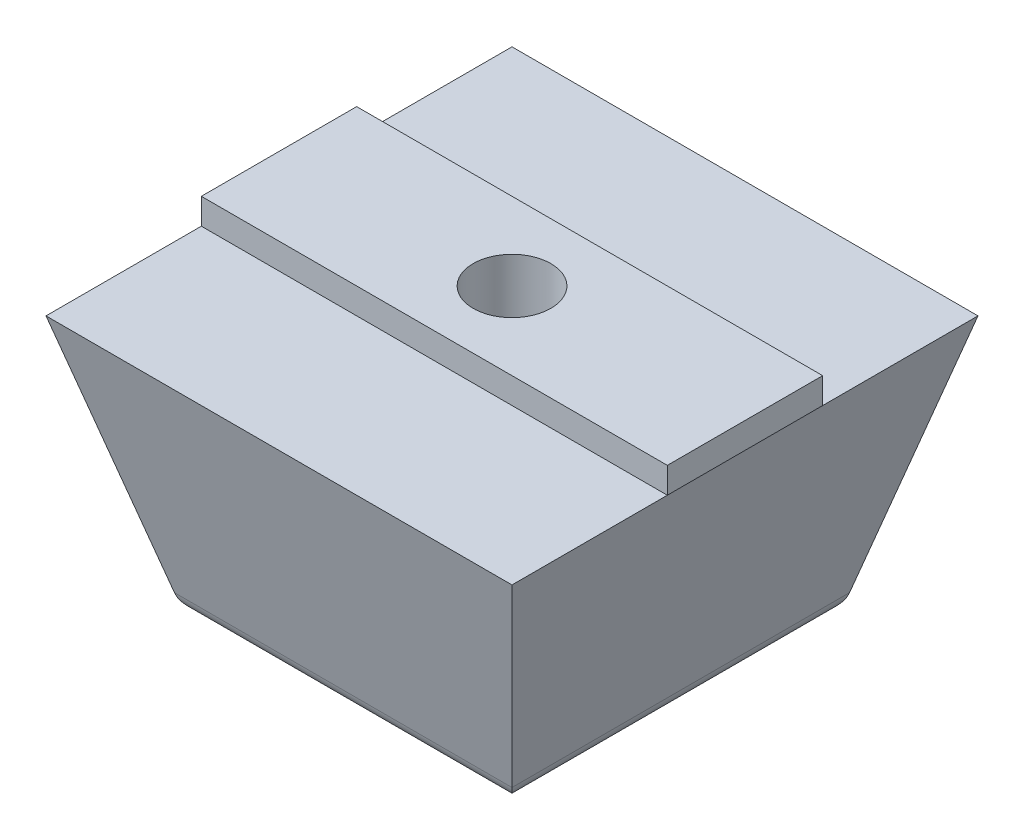
from build123d import *

# Parameters (mm, degrees)
SKETCH1_W           = 18
SKETCH1_H           = 18
BOSS_EXTRUDE1_DEPTH = 10
BOSS_EXTRUDE1_TAPER = 15
SKETCH5_W           = 18
SKETCH5_H           = 6
BOSS_EXTRUDE3_DEPTH = 3
FILLET2_R           = 1
CUT_EXTRUDE3_REACH  = 15
SKETCH6_R           = 1.5
SKETCH7_R           = 3
CUT_EXTRUDE4_DEPTH  = 8
SKETCH9_W           = 20
SKETCH9_H           = 6
CUT_EXTRUDE5_DEPTH  = 2
FILLET4_R           = 1


with BuildPart() as part:
    # Sketch1 → Boss-Extrude1 (new body)
    with BuildSketch(Plane(origin=(0, 0, 0), x_dir=(1, 0, 0), z_dir=(0, 1, 0))):
        Rectangle(SKETCH1_W, SKETCH1_H)
    extrude(amount=-BOSS_EXTRUDE1_DEPTH, taper=BOSS_EXTRUDE1_TAPER)

    # Sketch5 → Boss-Extrude3 (add)
    with BuildSketch(Plane(origin=(0, 0, 0), x_dir=(1, 0, 0), z_dir=(0, 1, 0))):
        Rectangle(SKETCH5_W, SKETCH5_H)
    extrude(amount=BOSS_EXTRUDE3_DEPTH)

    # Fillet2
    fillet2_edges = [part.edges().sort_by_distance(p)[0] for p in [
        (0, 3, 3),
        (0, 3, -3),
    ]]
    fillet(fillet2_edges, radius=FILLET2_R)

    # Sketch6 → Cut-Extrude3 (cut, up to next)
    with BuildSketch(Plane(origin=(0, 3, 0), x_dir=(1, 0, 0), z_dir=(0, 1, 0)), mode=Mode.PRIVATE) as cut_extrude3_sk1:
        Circle(SKETCH6_R)
    cut_extrude3_tool1 = extrude(cut_extrude3_sk1.sketch, amount=-CUT_EXTRUDE3_REACH, mode=Mode.PRIVATE) & part.part
    add(cut_extrude3_tool1.solids().sort_by_distance((0, 3, 0))[0], mode=Mode.SUBTRACT)

    # Sketch7 → Cut-Extrude4 (cut)
    with BuildSketch(Plane.XZ.offset(10)):
        Circle(SKETCH7_R)
    extrude(amount=-CUT_EXTRUDE4_DEPTH, mode=Mode.SUBTRACT)

    # Sketch9 → Cut-Extrude5 (cut)
    with BuildSketch(Plane(origin=(0, 3, 0), x_dir=(1, 0, 0), z_dir=(0, 1, 0))):
        Rectangle(SKETCH9_W, SKETCH9_H)
    extrude(amount=-CUT_EXTRUDE5_DEPTH, mode=Mode.SUBTRACT)

    # Fillet4
    fillet4_edges = [part.edges().sort_by_distance(p)[0] for p in [
        (-6.320508076, -10, 0),
        (0, -10, 6.320508076),
        (6.320508076, -10, 0),
        (0, -10, -6.320508076),
    ]]
    fillet(fillet4_edges, radius=FILLET4_R)


solid = part.part
